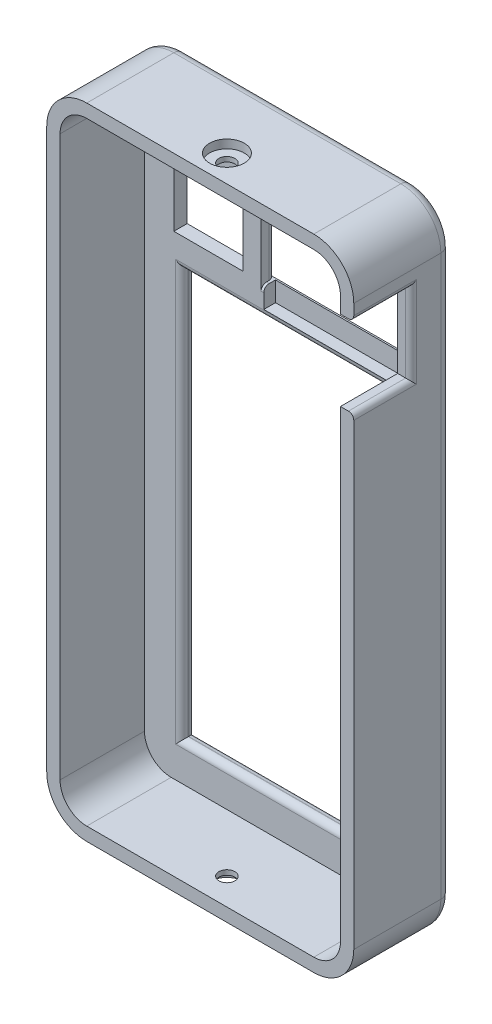
from build123d import *

# Parameters (mm, degrees)
BOSS_EXTRUDE1_DEPTH = 18.332422662
SHELL2_T            = -2.5
SKETCH2_W           = 26.4
SKETCH2_H           = 19.1
SKETCH2_W_2         = 13
SKETCH2_H_2         = 13
SKETCH2_W_3         = 38.578
SKETCH2_H_3         = 76.372933558
CUT_EXTRUDE1_DEPTH  = 4
FILLET1_R           = 2
FILLET2_R           = 1.2
FILLET4_R           = 1
CUT_EXTRUDE2_REACH  = 186.618
SKETCH3_W           = 10.732422662
SKETCH3_H           = 15
FILLET5_R           = 1
SKETCH6_W           = 26.474005188
SKETCH6_H           = 27.4
CUT_EXTRUDE5_DEPTH  = 2.2
SKETCH7_R           = 3.25
CUT_EXTRUDE6_DEPTH  = 1.6
SKETCH8_R           = 3.25
CUT_EXTRUDE7_DEPTH  = 1.6
SKETCH9_R           = 1.5
CUT_EXTRUDE8_DEPTH  = 5
SKETCH10_R          = 1.5
CUT_EXTRUDE9_DEPTH  = 5


with BuildPart() as part:
    # Sketch1 → Boss-Extrude1 (new body)
    with BuildSketch(Plane.XY):
        with BuildLine():
            Line((15.615664433, 54.513874967), (58.193664433, 54.513874967))
            ThreePointArc((58.193664433, 54.513874967), (63.496965292, 56.710574108), (65.693664433, 62.013874967))
            Line((65.693664433, 62.013874967), (65.693664433, 166.948874967))
            ThreePointArc((65.693664433, 166.948874967), (63.496965292, 172.252175826), (58.193664433, 174.448874967))
            Line((58.193664433, 174.448874967), (15.615664433, 174.448874967))
            ThreePointArc((15.615664433, 174.448874967), (10.312363574, 172.252175826), (8.115664433, 166.948874967))
            Line((8.115664433, 166.948874967), (8.115664433, 62.013874967))
            ThreePointArc((8.115664433, 62.013874967), (10.312363574, 56.710574108), (15.615664433, 54.513874967))
        make_face()
    extrude(amount=-BOSS_EXTRUDE1_DEPTH)

    # Shell2
    shell2_openings = [part.faces().sort_by_distance(p)[0] for p in [
        (36.904664433, 114.481374967, 0),
    ]]
    offset(amount=SHELL2_T, openings=shell2_openings, kind=Kind.INTERSECTION)

    # Sketch2 → Cut-Extrude1 (cut)
    with BuildSketch(Plane(origin=(0, 0, -18.332422662), x_dir=(-1, 0, 0), z_dir=(0, 0, -1))):
        with Locations((-45.679251594, 154.936808525)):
            Rectangle(SKETCH2_W, SKETCH2_H)
        with Locations((-22.615664433, 152.448874967)):
            Rectangle(SKETCH2_W_2, SKETCH2_H_2)
        with Locations((-36.904664433, 102.200341746)):
            Rectangle(SKETCH2_W_3, SKETCH2_H_3)
    extrude(amount=-CUT_EXTRUDE1_DEPTH, mode=Mode.SUBTRACT)

    # Fillet1
    fillet1_edges = [part.edges().sort_by_distance(p)[0] for p in [
        (63.496965292, 56.710574108, -18.332422662),
        (65.693664433, 114.481374967, -18.332422662),
        (63.496965292, 172.252175826, -18.332422662),
        (36.904664433, 174.448874967, -18.332422662),
        (10.312363574, 172.252175826, -18.332422662),
        (8.115664433, 114.481374967, -18.332422662),
        (10.312363574, 56.710574108, -18.332422662),
        (36.904664433, 54.513874967, -18.332422662),
    ]]
    fillet(fillet1_edges, radius=FILLET1_R)

    # Fillet2
    fillet2_edges = [part.edges().sort_by_distance(p)[0] for p in [
        (36.904664433, 64.013874967, -15.832422662),
        (17.615664433, 102.200341746, -15.832422662),
        (36.904664433, 140.386808525, -15.832422662),
        (56.193664433, 102.200341746, -15.832422662),
        (56.193664433, 102.200341746, -18.332422662),
        (36.904664433, 64.013874967, -18.332422662),
        (17.615664433, 102.200341746, -18.332422662),
        (36.904664433, 140.386808525, -18.332422662),
    ]]
    fillet(fillet2_edges, radius=FILLET2_R)

    # Fillet4
    fillet4_edges = [part.edges().sort_by_distance(p)[0] for p in [
        (45.679251594, 164.486808525, -15.832422662),
        (45.679251594, 145.386808525, -15.832422662),
        (32.479251594, 154.936808525, -18.332422662),
        (45.679251594, 164.486808525, -18.332422662),
        (58.879251594, 154.936808525, -18.332422662),
    ]]
    fillet(fillet4_edges, radius=FILLET4_R)

    # Sketch3 → Cut-Extrude2 (cut, up to next)
    with BuildSketch(Plane(origin=(65.693664433, 0, 0), x_dir=(0, 0, -1), z_dir=(1, 0, 0)), mode=Mode.PRIVATE) as cut_extrude2_sk1:
        with Locations((5.366211331, 156.448874967)):
            Rectangle(SKETCH3_W, SKETCH3_H)
    cut_extrude2_tool1 = extrude(cut_extrude2_sk1.sketch, amount=-CUT_EXTRUDE2_REACH, mode=Mode.PRIVATE) & part.part
    add(cut_extrude2_tool1.solids().sort_by_distance((65.693664, 156.448875, -5.366211))[0], mode=Mode.SUBTRACT)

    # Fillet5
    fillet5_edges = [part.edges().sort_by_distance(p)[0] for p in [
        (65.693664433, 148.948874967, -5.366211331),
        (65.693664433, 156.448874967, -10.732422662),
        (65.693664433, 163.948874967, -5.366211331),
    ]]
    fillet(fillet5_edges, radius=FILLET5_R)

    # Sketch6 → Cut-Extrude5 (cut)
    with BuildSketch(Plane.XY.offset(-15.832422662)):
        with Locations((46.216254188, 155.386808525)):
            Rectangle(SKETCH6_W, SKETCH6_H)
    extrude(amount=-CUT_EXTRUDE5_DEPTH, mode=Mode.SUBTRACT)

    # Sketch7 → Cut-Extrude6 (cut)
    with BuildSketch(Plane(origin=(0, 174.448874967, 0), x_dir=(1, 0, 0), z_dir=(0, 1, 0))):
        with Locations(Location((36.904664433, 5, 0), (0, 0, 270))):
            Circle(SKETCH7_R)
    extrude(amount=-CUT_EXTRUDE6_DEPTH, mode=Mode.SUBTRACT)

    # Sketch8 → Cut-Extrude7 (cut)
    with BuildSketch(Plane.XZ.offset(-54.513874967)):
        with Locations(Location((36.904664433, -5, 0), (0, 0, 90))):
            Circle(SKETCH8_R)
    extrude(amount=-CUT_EXTRUDE7_DEPTH, mode=Mode.SUBTRACT)

    # Sketch9 → Cut-Extrude8 (cut)
    with BuildSketch(Plane.XZ.offset(-56.113874967)):
        with Locations(Location((36.904664433, -5, 0), (0, 0, 270))):
            Circle(SKETCH9_R)
    extrude(amount=-CUT_EXTRUDE8_DEPTH, mode=Mode.SUBTRACT)

    # Sketch10 → Cut-Extrude9 (cut)
    with BuildSketch(Plane(origin=(0, 172.848874967, 0), x_dir=(1, 0, 0), z_dir=(0, 1, 0))):
        with Locations(Location((36.904664433, 5, 0), (0, 0, 90))):
            Circle(SKETCH10_R)
    extrude(amount=-CUT_EXTRUDE9_DEPTH, mode=Mode.SUBTRACT)


solid = part.part
